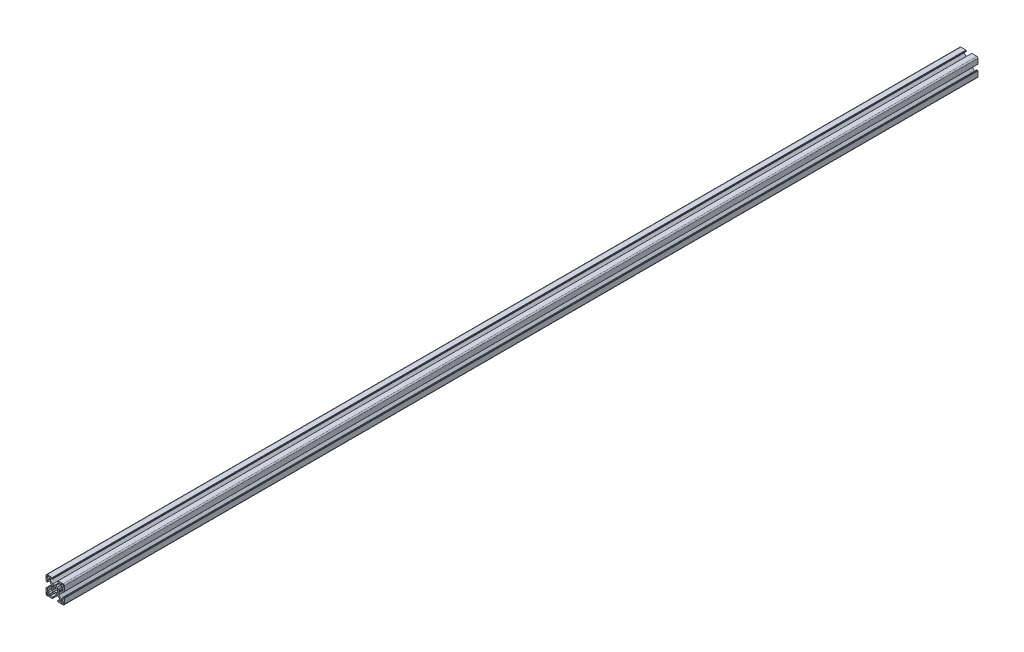
from build123d import *

# Parameters (mm, degrees)
SIGMA_PROFILE_DEPTH = 1500


with BuildPart() as part:
    # Sketch1 → Sigma Profile (new body)
    with BuildSketch(Plane.XY):
        with BuildLine():
            Line((96.56, 29.575148163), (97.459999946, 29.06))
            Line((97.459999946, 29.06), (100.764466193, 29.06))
            Line((100.764466193, 29.06), (104.810000327, 25.010000763))
            Line((104.810000327, 25.010000763), (104.810000327, 22.460001166))
            ThreePointArc((104.810000327, 22.460001166), (104.751421565, 22.318579525), (104.609999924, 22.260000763))
            Line((104.609999924, 22.260000763), (101.210000197, 22.260000763))
            ThreePointArc((101.210000197, 22.260000763), (100.785735989, 22.084264774), (100.61, 21.660000566))
            Line((100.61, 21.660000566), (100.61, 20.760000374))
            ThreePointArc((100.61, 20.760000374), (100.668578753, 20.618578753), (100.810000374, 20.56))
            Line((100.810000374, 20.56), (100.910000144, 20.56))
            ThreePointArc((100.910000144, 20.56), (101.05142109, 20.501421526), (101.109999564, 20.36000058))
            Line((101.109999564, 20.36000058), (101.109999564, 20.260000381))
            ThreePointArc((101.109999564, 20.260000381), (101.16857832, 20.118578755), (101.309999945, 20.06))
            Line((101.309999945, 20.06), (109.560000346, 20.06))
            ThreePointArc((109.560000346, 20.06), (110.974213664, 20.645786336), (111.56, 22.059999654))
            Line((111.56, 22.059999654), (111.56, 30.310000479))
            ThreePointArc((111.56, 30.310000479), (111.501421273, 30.451422036), (111.359999716, 30.510000763))
            Line((111.359999716, 30.510000763), (111.260000611, 30.510000763))
            ThreePointArc((111.260000611, 30.510000763), (111.118579054, 30.56857949), (111.060000327, 30.710001047))
            Line((111.060000327, 30.710001047), (111.060000327, 30.810000479))
            ThreePointArc((111.060000327, 30.810000479), (111.0014216, 30.951422036), (110.860000043, 31.010000763))
            Line((110.860000043, 31.010000763), (109.95999994, 31.010000763))
            ThreePointArc((109.95999994, 31.010000763), (109.535735606, 30.834264722), (109.359999564, 30.410000387))
            Line((109.359999564, 30.410000387), (109.359999564, 27.010000284))
            ThreePointArc((109.359999564, 27.010000284), (109.301420837, 26.868578727), (109.15999928, 26.81))
            Line((109.15999928, 26.81), (106.609999564, 26.81))
            Line((106.609999564, 26.81), (102.56446543, 30.855534134))
            Line((102.56446543, 30.855534134), (102.56446543, 34.160000381))
            Line((102.56446543, 34.160000381), (102.044852164, 35.06))
            Line((102.044852164, 35.06), (102.56446543, 35.959999619))
            Line((102.56446543, 35.959999619), (102.56446543, 39.264465866))
            Line((102.56446543, 39.264465866), (106.609999564, 43.31))
            Line((106.609999564, 43.31), (109.15999928, 43.31))
            ThreePointArc((109.15999928, 43.31), (109.301420837, 43.251421273), (109.359999564, 43.109999716))
            Line((109.359999564, 43.109999716), (109.359999564, 39.709999613))
            ThreePointArc((109.359999564, 39.709999613), (109.535735606, 39.285735278), (109.95999994, 39.109999237))
            Line((109.95999994, 39.109999237), (110.860000043, 39.109999237))
            ThreePointArc((110.860000043, 39.109999237), (111.0014216, 39.168577964), (111.060000327, 39.309999521))
            Line((111.060000327, 39.309999521), (111.060000327, 39.409998953))
            ThreePointArc((111.060000327, 39.409998953), (111.118579054, 39.55142051), (111.260000611, 39.609999237))
            Line((111.260000611, 39.609999237), (111.359999716, 39.609999237))
            ThreePointArc((111.359999716, 39.609999237), (111.501421273, 39.668577964), (111.56, 39.809999521))
            Line((111.56, 39.809999521), (111.56, 48.060000346))
            ThreePointArc((111.56, 48.060000346), (110.974213664, 49.474213664), (109.560000346, 50.06))
            Line((109.560000346, 50.06), (101.309999945, 50.06))
            ThreePointArc((101.309999945, 50.06), (101.16857832, 50.001421245), (101.109999564, 49.859999619))
            Line((101.109999564, 49.859999619), (101.109999564, 49.75999942))
            ThreePointArc((101.109999564, 49.75999942), (101.05142109, 49.618578474), (100.910000144, 49.56))
            Line((100.910000144, 49.56), (100.810000374, 49.56))
            ThreePointArc((100.810000374, 49.56), (100.668578753, 49.501421247), (100.61, 49.359999626))
            Line((100.61, 49.359999626), (100.61, 48.459999434))
            ThreePointArc((100.61, 48.459999434), (100.785735989, 48.035735226), (101.210000197, 47.859999237))
            Line((101.210000197, 47.859999237), (104.609999924, 47.859999237))
            ThreePointArc((104.609999924, 47.859999237), (104.751421565, 47.801420475), (104.810000327, 47.659998834))
            Line((104.810000327, 47.659998834), (104.810000327, 45.109999237))
            Line((104.810000327, 45.109999237), (100.764466193, 41.06))
            Line((100.764466193, 41.06), (97.459999946, 41.06))
            Line((97.459999946, 41.06), (96.56, 40.544851837))
            Line((96.56, 40.544851837), (95.660000054, 41.06))
            Line((95.660000054, 41.06), (92.355533807, 41.06))
            Line((92.355533807, 41.06), (88.309999673, 45.109999237))
            Line((88.309999673, 45.109999237), (88.309999673, 47.659998834))
            ThreePointArc((88.309999673, 47.659998834), (88.368578435, 47.801420475), (88.510000076, 47.859999237))
            Line((88.510000076, 47.859999237), (91.909999803, 47.859999237))
            ThreePointArc((91.909999803, 47.859999237), (92.334264011, 48.035735226), (92.51, 48.459999434))
            Line((92.51, 48.459999434), (92.51, 49.359999626))
            ThreePointArc((92.51, 49.359999626), (92.451421247, 49.501421247), (92.309999626, 49.56))
            Line((92.309999626, 49.56), (92.209999856, 49.56))
            ThreePointArc((92.209999856, 49.56), (92.06857891, 49.618578474), (92.010000436, 49.75999942))
            Line((92.010000436, 49.75999942), (92.010000436, 49.859999619))
            ThreePointArc((92.010000436, 49.859999619), (91.95142168, 50.001421245), (91.810000055, 50.06))
            Line((91.810000055, 50.06), (83.559999654, 50.06))
            ThreePointArc((83.559999654, 50.06), (82.145786336, 49.474213664), (81.56, 48.060000346))
            Line((81.56, 48.060000346), (81.56, 39.809999521))
            ThreePointArc((81.56, 39.809999521), (81.618578727, 39.668577964), (81.760000284, 39.609999237))
            Line((81.760000284, 39.609999237), (81.859999389, 39.609999237))
            ThreePointArc((81.859999389, 39.609999237), (82.001420946, 39.55142051), (82.059999673, 39.409998953))
            Line((82.059999673, 39.409998953), (82.059999673, 39.309999521))
            ThreePointArc((82.059999673, 39.309999521), (82.1185784, 39.168577964), (82.259999957, 39.109999237))
            Line((82.259999957, 39.109999237), (83.16000006, 39.109999237))
            ThreePointArc((83.16000006, 39.109999237), (83.584264394, 39.285735278), (83.760000436, 39.709999613))
            Line((83.760000436, 39.709999613), (83.760000436, 43.109999716))
            ThreePointArc((83.760000436, 43.109999716), (83.818579163, 43.251421273), (83.96000072, 43.31))
            Line((83.96000072, 43.31), (86.510000436, 43.31))
            Line((86.510000436, 43.31), (90.55553457, 39.264465866))
            Line((90.55553457, 39.264465866), (90.55553457, 35.959999619))
            Line((90.55553457, 35.959999619), (91.075147836, 35.06))
            Line((91.075147836, 35.06), (90.55553457, 34.160000381))
            Line((90.55553457, 34.160000381), (90.55553457, 30.855534134))
            Line((90.55553457, 30.855534134), (86.510000436, 26.81))
            Line((86.510000436, 26.81), (83.96000072, 26.81))
            ThreePointArc((83.96000072, 26.81), (83.818579163, 26.868578727), (83.760000436, 27.010000284))
            Line((83.760000436, 27.010000284), (83.760000436, 30.410000387))
            ThreePointArc((83.760000436, 30.410000387), (83.584264394, 30.834264722), (83.16000006, 31.010000763))
            Line((83.16000006, 31.010000763), (82.259999957, 31.010000763))
            ThreePointArc((82.259999957, 31.010000763), (82.1185784, 30.951422036), (82.059999673, 30.810000479))
            Line((82.059999673, 30.810000479), (82.059999673, 30.710001047))
            ThreePointArc((82.059999673, 30.710001047), (82.001420946, 30.56857949), (81.859999389, 30.510000763))
            Line((81.859999389, 30.510000763), (81.760000284, 30.510000763))
            ThreePointArc((81.760000284, 30.510000763), (81.618578727, 30.451422036), (81.56, 30.310000479))
            Line((81.56, 30.310000479), (81.56, 22.059999654))
            ThreePointArc((81.56, 22.059999654), (82.145786336, 20.645786336), (83.559999654, 20.06))
            Line((83.559999654, 20.06), (91.810000055, 20.06))
            ThreePointArc((91.810000055, 20.06), (91.95142168, 20.118578755), (92.010000436, 20.260000381))
            Line((92.010000436, 20.260000381), (92.010000436, 20.36000058))
            ThreePointArc((92.010000436, 20.36000058), (92.06857891, 20.501421526), (92.209999856, 20.56))
            Line((92.209999856, 20.56), (92.309999626, 20.56))
            ThreePointArc((92.309999626, 20.56), (92.451421247, 20.618578753), (92.51, 20.760000374))
            Line((92.51, 20.760000374), (92.51, 21.660000566))
            ThreePointArc((92.51, 21.660000566), (92.334264011, 22.084264774), (91.909999803, 22.260000763))
            Line((91.909999803, 22.260000763), (88.510000076, 22.260000763))
            ThreePointArc((88.510000076, 22.260000763), (88.368578435, 22.318579525), (88.309999673, 22.460001166))
            Line((88.309999673, 22.460001166), (88.309999673, 25.010000763))
            Line((88.309999673, 25.010000763), (92.355533807, 29.06))
            Line((92.355533807, 29.06), (95.660000054, 29.06))
            Line((95.660000054, 29.06), (96.56, 29.575148163))
        make_face()
        with BuildLine():
            Line((109.26000109, 48.760000398), (107.060000327, 48.760000398))
            ThreePointArc((107.060000327, 48.760000398), (106.352893543, 48.467107182), (106.060000327, 47.760000398))
            Line((106.060000327, 47.760000398), (106.060000327, 45.559999635))
            ThreePointArc((106.060000327, 45.559999635), (106.352893543, 44.852892851), (107.060000327, 44.559999635))
            Line((107.060000327, 44.559999635), (109.26000109, 44.559999635))
            ThreePointArc((109.26000109, 44.559999635), (109.967107874, 44.852892851), (110.26000109, 45.559999635))
            Line((110.26000109, 45.559999635), (110.26000109, 47.760000398))
            ThreePointArc((110.26000109, 47.760000398), (109.967107874, 48.467107182), (109.26000109, 48.760000398))
        make_face(mode=Mode.SUBTRACT)
        with BuildLine():
            Line((94.959870476, 38.340561767), (93.424070588, 39.578400903))
            ThreePointArc((93.424070588, 39.578400903), (92.678997741, 38.957155561), (92.054663108, 38.214669473))
            Line((92.054663108, 38.214669473), (93.279438268, 36.660129597))
            ThreePointArc((93.279438268, 36.660129597), (92.91, 35.06), (93.279438268, 33.459870403))
            Line((93.279438268, 33.459870403), (92.054663108, 31.905330527))
            ThreePointArc((92.054663108, 31.905330527), (92.678997741, 31.162844439), (93.424070588, 30.541599097))
            Line((93.424070588, 30.541599097), (94.959870476, 31.779438233))
            ThreePointArc((94.959870476, 31.779438233), (96.56, 31.41), (98.160129524, 31.779438233))
            Line((98.160129524, 31.779438233), (99.695929412, 30.541599097))
            ThreePointArc((99.695929412, 30.541599097), (100.441002259, 31.162844439), (101.065336892, 31.905330527))
            Line((101.065336892, 31.905330527), (99.840561732, 33.459870403))
            ThreePointArc((99.840561732, 33.459870403), (100.21, 35.06), (99.840561732, 36.660129597))
            Line((99.840561732, 36.660129597), (101.065336892, 38.214669473))
            ThreePointArc((101.065336892, 38.214669473), (100.441002259, 38.957155561), (99.695929412, 39.578400903))
            Line((99.695929412, 39.578400903), (98.160129524, 38.340561767))
            ThreePointArc((98.160129524, 38.340561767), (96.56, 38.71), (94.959870476, 38.340561767))
        make_face(mode=Mode.SUBTRACT)
        with BuildLine():
            Line((83.85999891, 21.359999602), (86.059999673, 21.359999602))
            ThreePointArc((86.059999673, 21.359999602), (86.767106457, 21.652892818), (87.059999673, 22.359999602))
            Line((87.059999673, 22.359999602), (87.059999673, 24.560000365))
            ThreePointArc((87.059999673, 24.560000365), (86.767106457, 25.267107149), (86.059999673, 25.560000365))
            Line((86.059999673, 25.560000365), (83.85999891, 25.560000365))
            ThreePointArc((83.85999891, 25.560000365), (83.152892126, 25.267107149), (82.85999891, 24.560000365))
            Line((82.85999891, 24.560000365), (82.85999891, 22.359999602))
            ThreePointArc((82.85999891, 22.359999602), (83.152892126, 21.652892818), (83.85999891, 21.359999602))
        make_face(mode=Mode.SUBTRACT)
        with BuildLine():
            Line((110.26000109, 22.359999602), (110.26000109, 24.560000365))
            ThreePointArc((110.26000109, 24.560000365), (109.967107874, 25.267107149), (109.26000109, 25.560000365))
            Line((109.26000109, 25.560000365), (107.060000327, 25.560000365))
            ThreePointArc((107.060000327, 25.560000365), (106.352893543, 25.267107149), (106.060000327, 24.560000365))
            Line((106.060000327, 24.560000365), (106.060000327, 22.359999602))
            ThreePointArc((106.060000327, 22.359999602), (106.352893543, 21.652892818), (107.060000327, 21.359999602))
            Line((107.060000327, 21.359999602), (109.26000109, 21.359999602))
            ThreePointArc((109.26000109, 21.359999602), (109.967107874, 21.652892818), (110.26000109, 22.359999602))
        make_face(mode=Mode.SUBTRACT)
        with BuildLine():
            Line((86.059999673, 48.760000398), (83.85999891, 48.760000398))
            ThreePointArc((83.85999891, 48.760000398), (83.152892126, 48.467107182), (82.85999891, 47.760000398))
            Line((82.85999891, 47.760000398), (82.85999891, 45.559999635))
            ThreePointArc((82.85999891, 45.559999635), (83.152892126, 44.852892851), (83.85999891, 44.559999635))
            Line((83.85999891, 44.559999635), (86.059999673, 44.559999635))
            ThreePointArc((86.059999673, 44.559999635), (86.767106457, 44.852892851), (87.059999673, 45.559999635))
            Line((87.059999673, 45.559999635), (87.059999673, 47.760000398))
            ThreePointArc((87.059999673, 47.760000398), (86.767106457, 48.467107182), (86.059999673, 48.760000398))
        make_face(mode=Mode.SUBTRACT)
    extrude(amount=SIGMA_PROFILE_DEPTH)


solid = part.part
